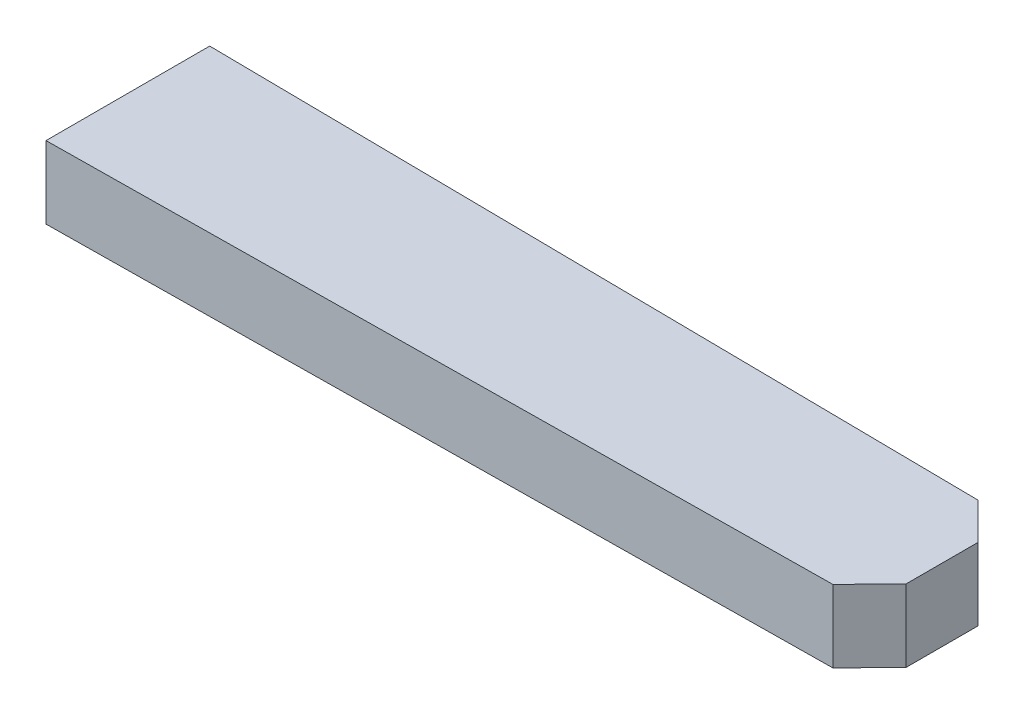
from build123d import *

# Parameters (mm, degrees)
BOSS_EXTRUDE1_DEPTH   = 4
CHAMFER2_SIZE2        = 2
CHAMFER2_SIZE         = 2.023746482
CHAMFER2_EDGE_2_SIZE2 = 2
CHAMFER2_EDGE_2_SIZE  = 2.023746482


with BuildPart() as part:
    # Sketch2 → Boss-Extrude1 (new body)
    with BuildSketch(Plane(origin=(0, 0, 0), x_dir=(1, 0, 0), z_dir=(0, 1, 0))):
        Polygon((0, 9.05), (45, 8.525), (45, 0.525), (0, 0), align=None)
    extrude(amount=BOSS_EXTRUDE1_DEPTH)

    # Chamfer2
    chamfer2_edges = [part.edges().sort_by_distance(p)[0] for p in [
        (45, 2, -8.525),
    ]]
    chamfer(chamfer2_edges, length=CHAMFER2_SIZE, length2=CHAMFER2_SIZE2)

    # Chamfer2 edge 2
    chamfer2_edge_2_edges = [part.edges().sort_by_distance(p)[0] for p in [
        (45, 2, -0.525),
    ]]
    chamfer(chamfer2_edge_2_edges, length=CHAMFER2_EDGE_2_SIZE, length2=CHAMFER2_EDGE_2_SIZE2)


solid = part.part
